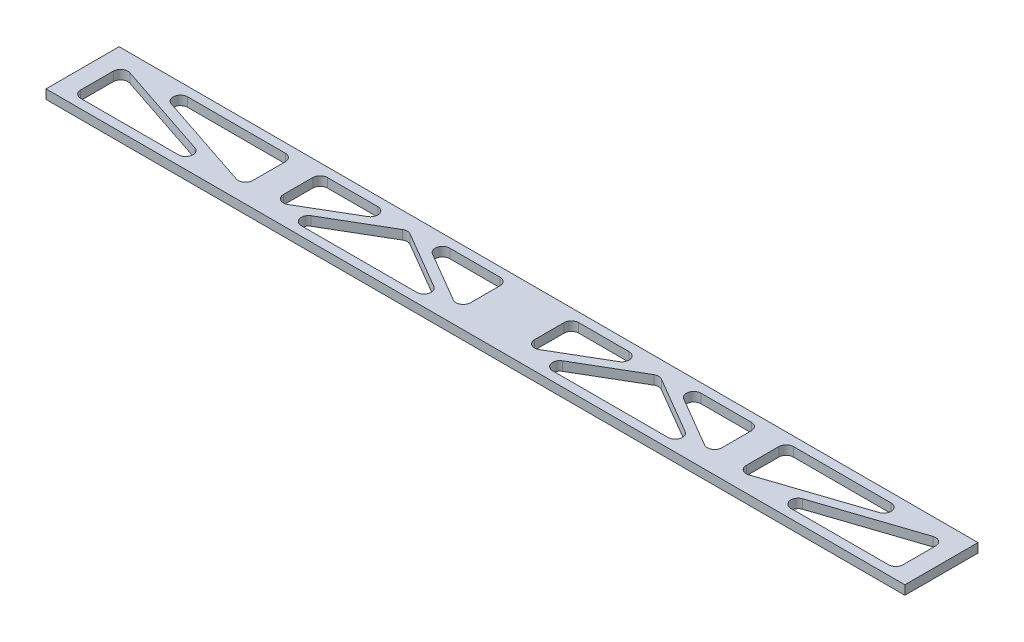
from build123d import *

# Parameters (mm, degrees)
SKETCH1_W           = 298.45
SKETCH1_H           = 25.4
BOSS_EXTRUDE1_DEPTH = 3.175
CUT_EXTRUDE1_DEPTH  = 4.175
FILLET1_R           = 2.54


with BuildPart() as part:
    # Sketch1 → Boss-Extrude1 (new body)
    with BuildSketch(Plane(origin=(0, 0, 0), x_dir=(1, 0, 0), z_dir=(0, 1, 0))):
        Rectangle(SKETCH1_W, SKETCH1_H)
    extrude(amount=BOSS_EXTRUDE1_DEPTH)

    # Sketch2 → Cut-Extrude1 (cut, through all)
    with BuildSketch(Plane(origin=(0, 3.175, 0), x_dir=(1, 0, 0), z_dir=(0, 1, 0))):
        Polygon((-142.875, -9.525), (-90.745115786, -9.525), (-142.875, 7.851628071), align=None)
        Polygon((-85.725, -7.851628071), (-85.725, 9.525), (-137.854884214, 9.525), align=None)
        Polygon((-76.2, -7.685517516), (-46.798699244, 9.525), (-76.2, 9.525), align=None)
        Polygon((-73.057550756, -9.525), (-14.254949244, -9.525), (-43.65625, 7.685517516), align=None)
        Polygon((-11.1125, -7.685517516), (-11.1125, 9.525), (-40.513800756, 9.525), align=None)
        Polygon((11.1125, -7.685517516), (40.513800756, 9.525), (11.1125, 9.525), align=None)
        Polygon((14.254949244, -9.525), (73.057550756, -9.525), (43.65625, 7.685517516), align=None)
        Polygon((76.2, -7.685517516), (76.2, 9.525), (46.798699244, 9.525), align=None)
        Polygon((85.725, -7.851628071), (137.854884214, 9.525), (85.725, 9.525), align=None)
        Polygon((90.745115786, -9.525), (142.875, -9.525), (142.875, 7.851628071), align=None)
    extrude(amount=-CUT_EXTRUDE1_DEPTH, mode=Mode.SUBTRACT)

    # Fillet1
    fillet1_edges = [part.edges().sort_by_distance(p)[0] for p in [
        (-43.65625, 1.5875, -7.685517516),
        (-14.254949244, 1.5875, 9.525),
        (-73.057550756, 1.5875, 9.525),
        (-40.513800756, 1.5875, -9.525),
        (-11.1125, 1.5875, -9.525),
        (-11.1125, 1.5875, 7.685517516),
        (-76.2, 1.5875, 7.685517516),
        (-76.2, 1.5875, -9.525),
        (-46.798699244, 1.5875, -9.525),
        (-85.725, 1.5875, 7.851628071),
        (-137.854884214, 1.5875, -9.525),
        (-85.725, 1.5875, -9.525),
        (85.725, 1.5875, 7.851628071),
        (85.725, 1.5875, -9.525),
        (137.854884214, 1.5875, -9.525),
        (46.798699244, 1.5875, -9.525),
        (76.2, 1.5875, -9.525),
        (76.2, 1.5875, 7.685517516),
        (11.1125, 1.5875, 7.685517516),
        (11.1125, 1.5875, -9.525),
        (40.513800756, 1.5875, -9.525),
        (43.65625, 1.5875, -7.685517516),
        (73.057550756, 1.5875, 9.525),
        (14.254949244, 1.5875, 9.525),
        (90.745115786, 1.5875, 9.525),
        (142.875, 1.5875, -7.851628071),
        (142.875, 1.5875, 9.525),
        (-90.745115786, 1.5875, 9.525),
        (-142.875, 1.5875, 9.525),
        (-142.875, 1.5875, -7.851628071),
    ]]
    fillet(fillet1_edges, radius=FILLET1_R)


solid = part.part
